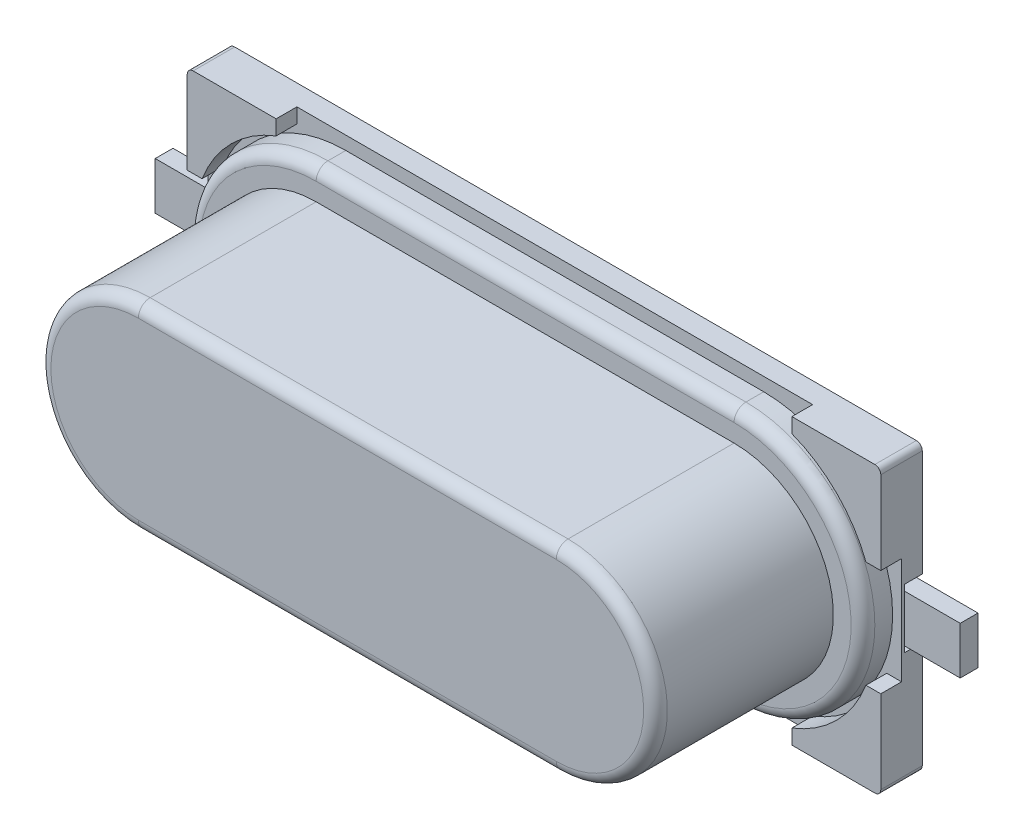
from build123d import *

# Parameters (mm, degrees)
DODANIE_WYCI_GNI_CIE1_DEPTH      = 0.7
SZKIC2_W                         = 4
SZKIC2_H                         = 1
DODANIE_WYCI_GNI_CIE2_DEPTH      = 0.4
WYTNIJ_WYCI_GNI_CIE1_DEPTH       = 0.35
DODANIE_WYCI_GNI_CIE3_DEPTH      = 3.5
SZKIC5_OUTSIDE_W                 = 16.344
SZKIC5_OUTSIDE_H                 = 9.444
WYTNIJ_WYCI_GNI_CIE2_DEPTH       = 3
ZAOKR_GLENIE1_R                  = 0.2
ZAOKR_GLENIE2_R                  = 0.2
SZKIC6_W                         = 0.3
SZKIC6_H                         = 0.8
DODANIE_WYCI_GNI_CIE4_DEPTH      = 0.94
DODANIE_WYCI_GNI_CIE4_DEPTH_BACK = 3


with BuildPart() as part:
    # Szkic1 → Dodanie-wyciągnięcie1 (new body)
    with BuildSketch(Plane.XY):
        with BuildLine():
            Line((0, 0), (-11.5, 0))
            ThreePointArc((-11.5, 0), (-11.570710678, -0.029289322), (-11.6, -0.1))
            Line((-11.6, -0.1), (-11.6, -1.9))
            Line((-11.6, -1.9), (-7.6, -1.9))
            Line((-7.6, -1.9), (-7.6, -2.9))
            Line((-7.6, -2.9), (-11.6, -2.9))
            Line((-11.6, -2.9), (-11.6, -4.7))
            ThreePointArc((-11.6, -4.7), (-11.570710678, -4.770710678), (-11.5, -4.8))
            Line((-11.5, -4.8), (0, -4.8))
            ThreePointArc((0, -4.8), (0.070710678, -4.770710678), (0.1, -4.7))
            Line((0.1, -4.7), (0.1, -2.9))
            Line((0.1, -2.9), (-3.9, -2.9))
            Line((-3.9, -2.9), (-3.9, -1.9))
            Line((-3.9, -1.9), (0.1, -1.9))
            Line((0.1, -1.9), (0.1, -0.1))
            ThreePointArc((0.1, -0.1), (0.070710678, -0.029289322), (0, 0))
        make_face()
    extrude(amount=DODANIE_WYCI_GNI_CIE1_DEPTH)

    # Szkic2 → Dodanie-wyciągnięcie2 (add)
    with BuildSketch(Plane.XY.offset(0.7)):
        with Locations((-9.6, -2.4)):
            Rectangle(SZKIC2_W, SZKIC2_H)
        with Locations((-1.9, -2.4)):
            Rectangle(SZKIC2_W, SZKIC2_H)
    extrude(amount=-DODANIE_WYCI_GNI_CIE2_DEPTH)

    # Szkic3 → Wytnij-wyciągnięcie1 (cut)
    with BuildSketch(Plane.XY.offset(0.7)):
        with BuildLine():
            Line((-1.4, -0.25), (-1.4, 0))
            Line((-1.4, 0), (-10.1, 0))
            Line((-10.1, 0), (-10.1, -0.25))
            ThreePointArc((-10.1, -0.25), (-10.857388458, -0.742611542), (-11.35, -1.5))
            Line((-11.35, -1.5), (-11.6, -1.5))
            Line((-11.6, -1.5), (-11.6, -3.3))
            Line((-11.6, -3.3), (-11.35, -3.3))
            ThreePointArc((-11.35, -3.3), (-10.857388458, -4.057388458), (-10.1, -4.55))
            Line((-10.1, -4.55), (-10.1, -4.8))
            Line((-10.1, -4.8), (-1.4, -4.8))
            Line((-1.4, -4.8), (-1.4, -4.55))
            ThreePointArc((-1.4, -4.55), (-0.642611542, -4.057388458), (-0.15, -3.3))
            Line((-0.15, -3.3), (0.1, -3.3))
            Line((0.1, -3.3), (0.1, -1.5))
            Line((0.1, -1.5), (-0.15, -1.5))
            ThreePointArc((-0.15, -1.5), (-0.642611542, -0.742611542), (-1.4, -0.25))
        make_face()
    extrude(amount=-WYTNIJ_WYCI_GNI_CIE1_DEPTH, mode=Mode.SUBTRACT)


with BuildPart() as body_2:
    # Szkic4 → Dodanie-wyciągnięcie3 (new body)
    with BuildSketch(Plane.XY.offset(0.35)):
        with BuildLine():
            Line((-2.225, -0.225), (-9.275, -0.225))
            ThreePointArc((-9.275, -0.225), (-11.45, -2.4), (-9.275, -4.575))
            Line((-9.275, -4.575), (-2.225, -4.575))
            ThreePointArc((-2.225, -4.575), (-0.05, -2.4), (-2.225, -0.225))
        make_face()
    extrude(amount=DODANIE_WYCI_GNI_CIE3_DEPTH)

    # Szkic5 outside → Wytnij-wyciągnięcie2 (cut)
    with BuildSketch(Plane.XY.offset(3.85)):
        with Locations((-5.75, -2.4)):
            Rectangle(SZKIC5_OUTSIDE_W, SZKIC5_OUTSIDE_H)
        with BuildLine():
            Line((-2.225, -0.725), (-9.275, -0.725))
            ThreePointArc((-9.275, -0.725), (-10.95, -2.4), (-9.275, -4.075))
            Line((-9.275, -4.075), (-2.225, -4.075))
            ThreePointArc((-2.225, -4.075), (-0.55, -2.4), (-2.225, -0.725))
        make_face(mode=Mode.SUBTRACT)
    extrude(amount=-WYTNIJ_WYCI_GNI_CIE2_DEPTH, mode=Mode.SUBTRACT)

    # Zaokrąglenie1
    zaokr_glenie1_edges = [body_2.edges().sort_by_distance(p)[0] for p in [
        (-0.55, -2.4, 3.85),
        (-5.75, -4.075, 3.85),
        (-10.95, -2.4, 3.85),
        (-5.75, -0.725, 3.85),
    ]]
    fillet(zaokr_glenie1_edges, radius=ZAOKR_GLENIE1_R)

    # Zaokrąglenie2
    zaokr_glenie2_edges = [body_2.edges().sort_by_distance(p)[0] for p in [
        (-5.75, -4.575, 0.85),
        (-0.05, -2.4, 0.85),
        (-5.75, -0.225, 0.85),
        (-11.45, -2.4, 0.85),
    ]]
    fillet(zaokr_glenie2_edges, radius=ZAOKR_GLENIE2_R)


with BuildPart() as body_3:
    # Szkic6 → Dodanie-wyciągnięcie4 (new body, two sides)
    with BuildSketch(Plane(origin=(0.1, 0, 0), x_dir=(0, 0, -1), z_dir=(1, 0, 0))) as dodanie_wyci_gni_cie4_sk:
        with Locations((-0.15, -2.4)):
            Rectangle(SZKIC6_W, SZKIC6_H)
    extrude(amount=DODANIE_WYCI_GNI_CIE4_DEPTH)
    extrude(dodanie_wyci_gni_cie4_sk.sketch, amount=-DODANIE_WYCI_GNI_CIE4_DEPTH_BACK)


with BuildPart() as body_4:
    # Lustro1: mirrored copy
    add(body_3.part.mirror(Plane(origin=(-5.75, 0, 0), x_dir=(0, 0, 1), z_dir=(1, 0, 0))))


solid = Compound([part.part, body_2.part, body_3.part, body_4.part])
